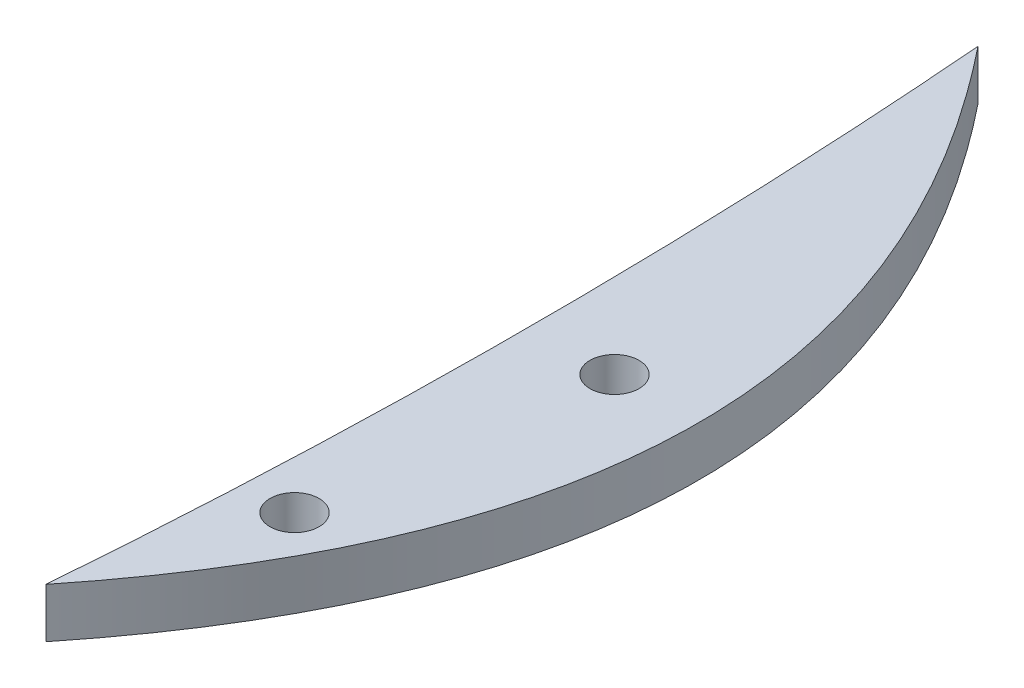
from build123d import *

# Parameters (mm, degrees)
BOSS_EXTRUDE1_DEPTH = 4
SKETCH3_R           = 1.975
CUT_EXTRUDE1_DEPTH  = 5.0000001


with BuildPart() as part:
    # Sketch1 → Boss-Extrude1 (new body)
    with BuildSketch(Plane(origin=(0, 0, 0), x_dir=(1, 0, 0), z_dir=(0, 1, 0))):
        with BuildLine():
            add(Edge.make_bspline(
                [(-16.833976834, -19.845559846), (13.166023166, 17.654440154), (-16.833976834, 55.154440154)],
                knots=[0, 0, 0, 1, 1, 1], degree=2))
            add(Edge.make_bspline(
                [(-16.833976834, -19.845559846), (-13.833976834, 17.654440154), (-16.833976834, 55.154440154)],
                knots=[0, 0, 0, 1, 1, 1], degree=2))
        make_face()
    extrude(amount=BOSS_EXTRUDE1_DEPTH)

    # Sketch3 → Cut-Extrude1 (cut, through all)
    with BuildSketch(Plane(origin=(0, 4, 0), x_dir=(1, 0, 0), z_dir=(0, 1, 0))):
        with Locations((-8.583976834, 17.654440137)):
            Circle(SKETCH3_R)
        with Locations((-11.833976834, -4.845559846)):
            Circle(SKETCH3_R)
    extrude(amount=-CUT_EXTRUDE1_DEPTH, mode=Mode.SUBTRACT)


solid = part.part
